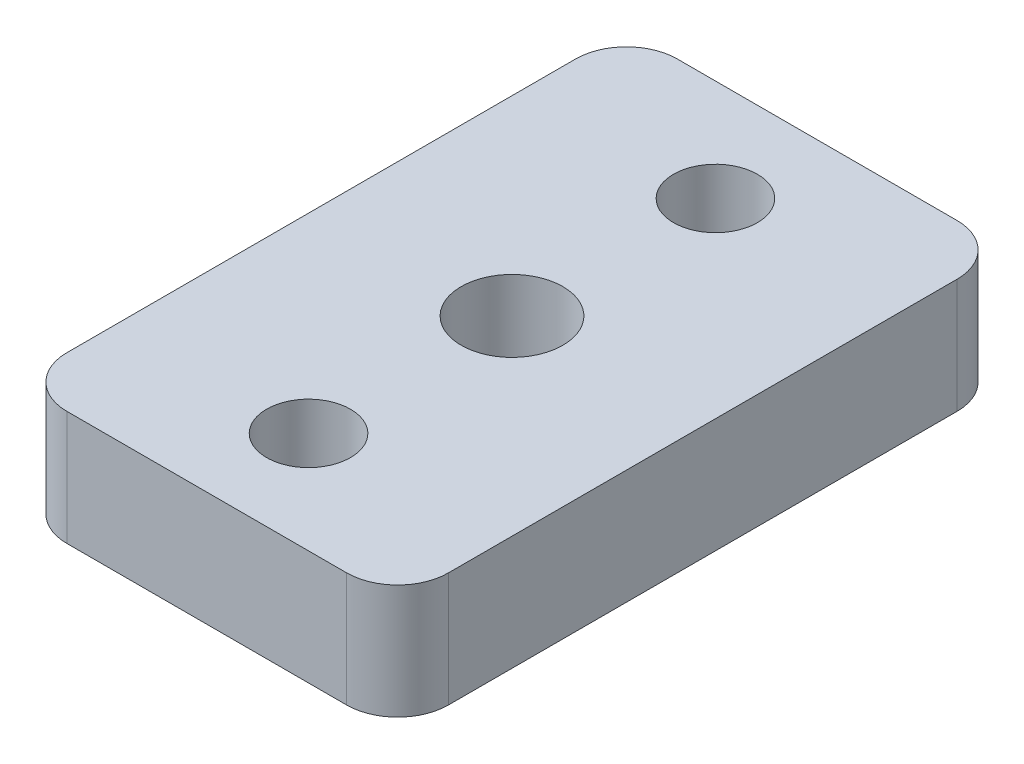
from build123d import *

# Parameters (mm, degrees)
SKETCH1_R           = 2
SKETCH1_R_2         = 1.65
BOSS_EXTRUDE1_DEPTH = 4.5


with BuildPart() as part:
    # Sketch1 → Boss-Extrude1 (new body)
    with BuildSketch(Plane(origin=(0, 4.5, 0), x_dir=(1, 0, 0), z_dir=(0, 1, 0))):
        with BuildLine():
            Line((5.5, 12), (-5.5, 12))
            ThreePointArc((-5.5, 12), (-6.914213562, 11.414213562), (-7.5, 10))
            Line((-7.5, 10), (-7.5, -10))
            ThreePointArc((-7.5, -10), (-6.914213562, -11.414213562), (-5.5, -12))
            Line((-5.5, -12), (5.5, -12))
            ThreePointArc((5.5, -12), (6.914213562, -11.414213562), (7.5, -10))
            Line((7.5, -10), (7.5, 10))
            ThreePointArc((7.5, 10), (6.914213562, 11.414213562), (5.5, 12))
        make_face()
        Circle(SKETCH1_R, mode=Mode.SUBTRACT)
        with Locations((0, -8)):
            Circle(SKETCH1_R_2, mode=Mode.SUBTRACT)
        with Locations((0, 8)):
            Circle(SKETCH1_R_2, mode=Mode.SUBTRACT)
    extrude(amount=-BOSS_EXTRUDE1_DEPTH)


solid = part.part
